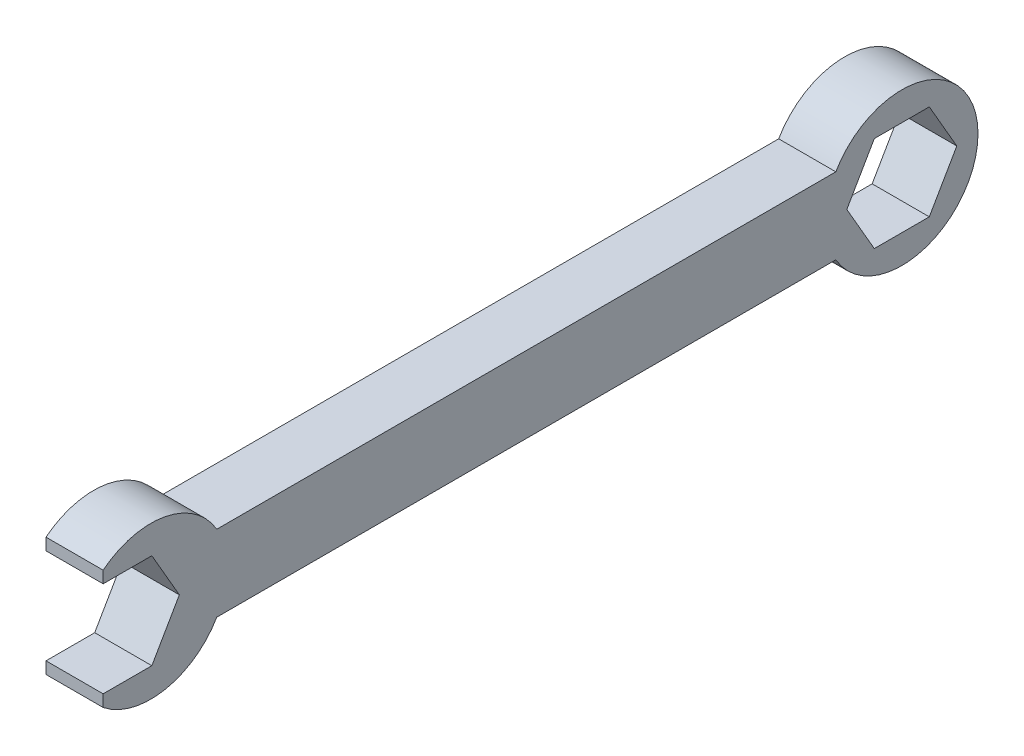
from build123d import *

# Parameters (mm, degrees)
BOSS_EXTRUDE1_DEPTH = 7.62


with BuildPart() as part:
    # Sketch1 → Boss-Extrude1 (new body)
    with BuildSketch(Plane(origin=(0, 0, 0), x_dir=(0, 0, -1), z_dir=(1, 0, 0))):
        with BuildLine():
            Line((-41.275, 5.08), (41.275, 5.08))
            ThreePointArc((41.275, 5.08), (60.233818102, 0), (41.275, -5.08))
            Line((41.275, -5.08), (-41.275, -5.08))
            ThreePointArc((-41.275, -5.08), (-48.194606038, -9.984696391), (-56.423818102, -7.931147458))
            Line((-56.423818102, -7.931147458), (-56.423818102, -6.35))
            Line((-56.423818102, -6.35), (-49.929992312, -6.35))
            Line((-49.929992312, -6.35), (-46.263818102, 0))
            Line((-46.263818102, 0), (-49.929992312, 6.35))
            Line((-49.929992312, 6.35), (-56.423818102, 6.35))
            Line((-56.423818102, 6.35), (-56.423818102, 7.931147458))
            ThreePointArc((-56.423818102, 7.931147458), (-48.194606038, 9.984696391), (-41.275, 5.08))
        make_face()
        Polygon((57.406166521, 0), (53.739992312, 6.35), (46.407643893, 6.35), (42.741469684, 0), (46.407643893, -6.35), (53.739992312, -6.35), align=None, mode=Mode.SUBTRACT)
    extrude(amount=BOSS_EXTRUDE1_DEPTH)


solid = part.part
